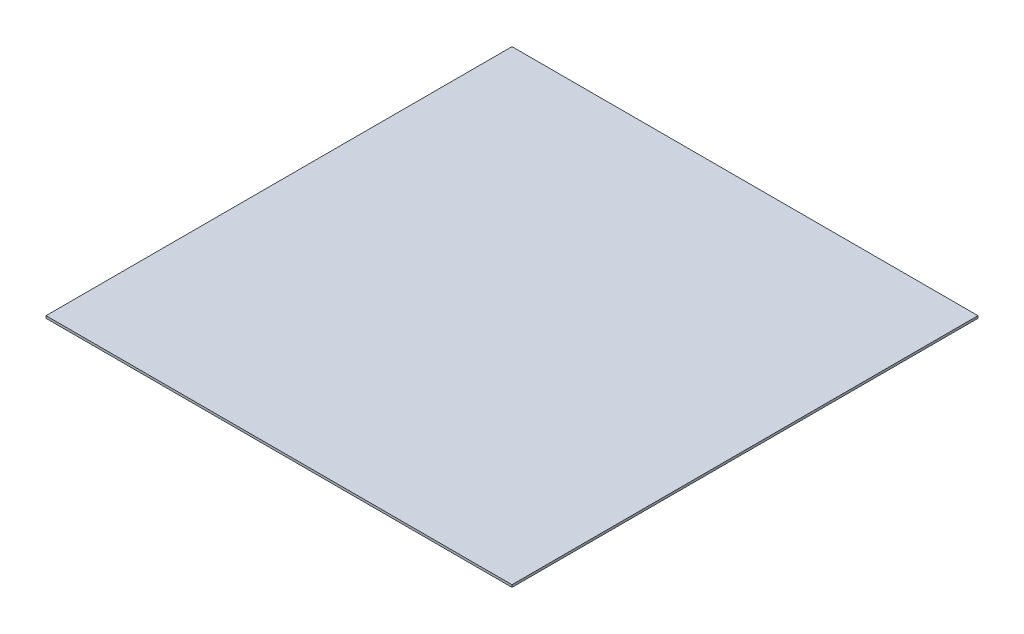
from build123d import *

# Parameters (mm, degrees)
SKETCH1_W           = 100
SKETCH1_H           = 100
BOSS_EXTRUDE1_DEPTH = 0.5


with BuildPart() as part:
    # Sketch1 → Boss-Extrude1 (new body)
    with BuildSketch(Plane(origin=(0, 0, 0), x_dir=(1, 0, 0), z_dir=(0, 1, 0))):
        Rectangle(SKETCH1_W, SKETCH1_H)
    extrude(amount=BOSS_EXTRUDE1_DEPTH)


solid = part.part
